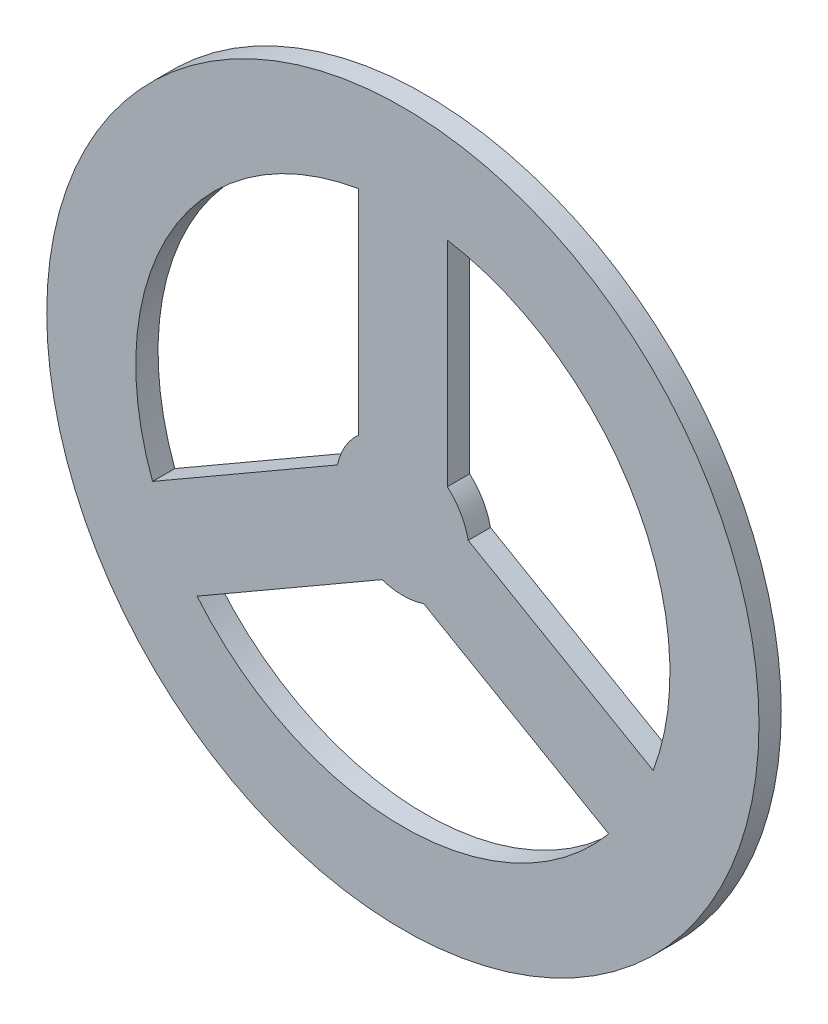
from build123d import *

# Parameters (mm, degrees)
SKETCH1_R           = 101.6
BOSS_EXTRUDE1_DEPTH = 6.35
SCALE1_SCALE        = 0.5


with BuildPart() as part:
    # Sketch1 → Boss-Extrude1 (new body)
    with BuildSketch(Plane.XY):
        Circle(SKETCH1_R)
        with BuildLine():
            Line((-12.7, 14.199031657), (-12.7, 75.134213245))
            ThreePointArc((-12.7, 75.134213245), (-65.991135768, 38.1), (-71.418137364, -26.568583995))
            Line((-71.418137364, -26.568583995), (-18.646722124, 3.8990068))
            ThreePointArc((-18.646722124, 3.8990068), (-16.497783942, 9.525), (-12.7, 14.199031657))
        make_face(mode=Mode.SUBTRACT)
        with BuildLine():
            Line((12.7, 14.199031657), (12.7, 75.134213245))
            ThreePointArc((12.7, 75.134213245), (65.991135768, 38.1), (71.418137364, -26.568583995))
            Line((71.418137364, -26.568583995), (18.646722124, 3.8990068))
            ThreePointArc((18.646722124, 3.8990068), (16.497783942, 9.525), (12.7, 14.199031657))
        make_face(mode=Mode.SUBTRACT)
        with BuildLine():
            Line((5.946722124, -18.098038457), (58.718137364, -48.565629251))
            ThreePointArc((58.718137364, -48.565629251), (0, -76.2), (-58.718137364, -48.565629251))
            Line((-58.718137364, -48.565629251), (-5.946722124, -18.098038457))
            ThreePointArc((-5.946722124, -18.098038457), (0, -19.05), (5.946722124, -18.098038457))
        make_face(mode=Mode.SUBTRACT)
    extrude(amount=BOSS_EXTRUDE1_DEPTH)


with BuildPart() as part_1:
    # Scale1: scaled about (0, 0, 3.175)
    add(part.part.scale(SCALE1_SCALE).moved(Location((0, 0, 1.5875))))


solid = part_1.part
